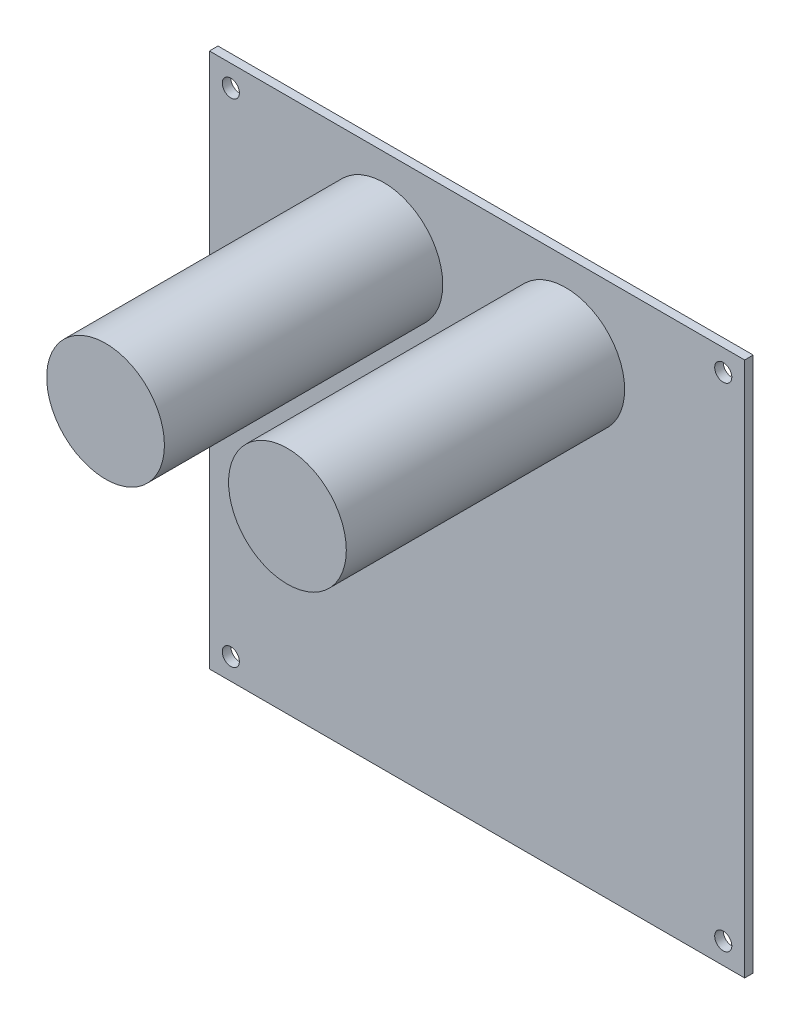
from build123d import *

# Parameters (mm, degrees)
ESQUISSE1_W        = 100
ESQUISSE1_H        = 100
ESQUISSE1_R        = 1.6
BOSS_EXTRU_1_DEPTH = 1.6
ESQUISSE2_R        = 11
BOSS_EXTRU_2_DEPTH = 52


with BuildPart() as part:
    # Esquisse1 → Boss.-Extru.1 (new body)
    with BuildSketch(Plane.XY):
        Rectangle(ESQUISSE1_W, ESQUISSE1_H)
        with Locations((-46, 46)):
            Circle(ESQUISSE1_R, mode=Mode.SUBTRACT)
        with Locations((46, 46)):
            Circle(ESQUISSE1_R, mode=Mode.SUBTRACT)
        with Locations((-46, -46)):
            Circle(ESQUISSE1_R, mode=Mode.SUBTRACT)
        with Locations((46, -46)):
            Circle(ESQUISSE1_R, mode=Mode.SUBTRACT)
    extrude(amount=BOSS_EXTRU_1_DEPTH)

    # Esquisse2 → Boss.-Extru.2 (add)
    with BuildSketch(Plane.XY.offset(1.6)):
        with Locations((-17.405055541, 34)):
            Circle(ESQUISSE2_R)
        with Locations((16.577398103, 34)):
            Circle(ESQUISSE2_R)
    extrude(amount=BOSS_EXTRU_2_DEPTH)


solid = part.part
